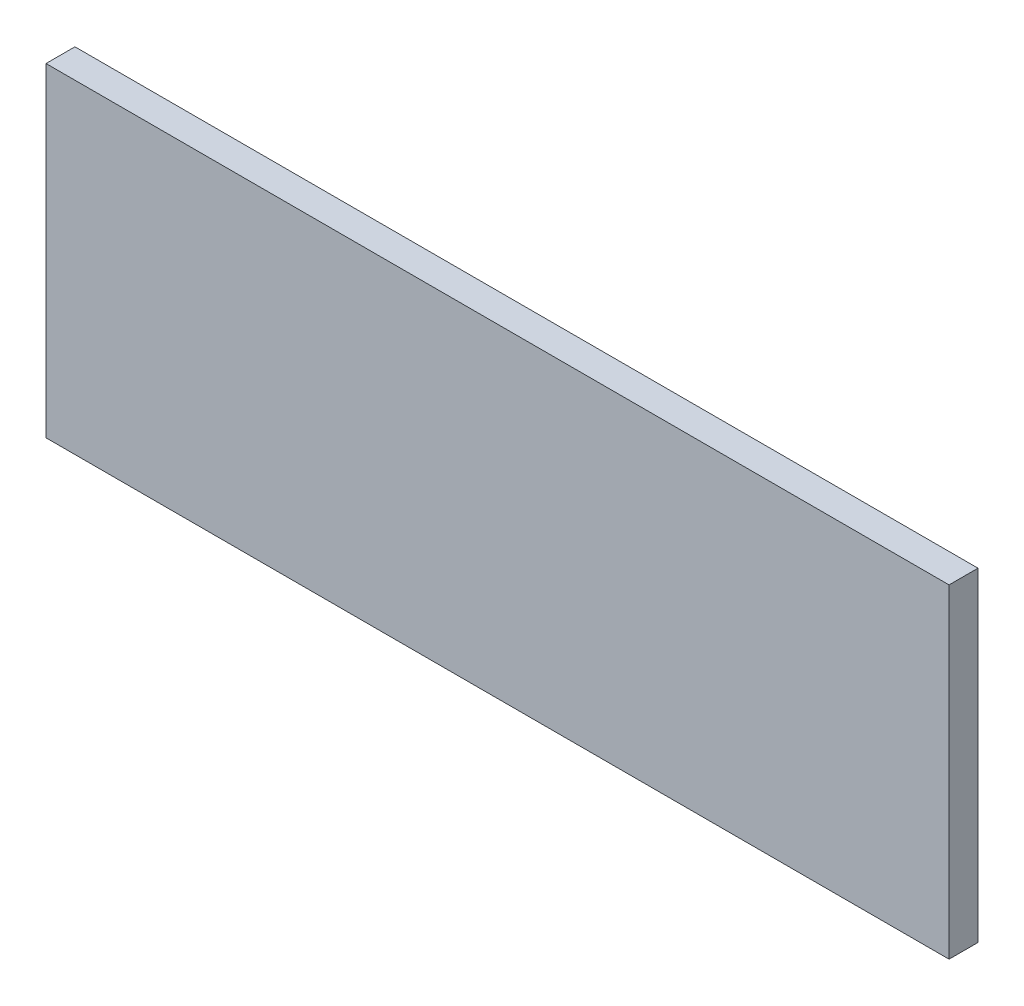
from build123d import *

# Parameters (mm, degrees)
SKETCH1_W           = 78
SKETCH1_H           = 28
BOSS_EXTRUDE1_DEPTH = 2.5


with BuildPart() as part:
    # Sketch1 → Boss-Extrude1 (new body)
    with BuildSketch(Plane.XY):
        with Locations((2.884955752, 2.921828909)):
            Rectangle(SKETCH1_W, SKETCH1_H)
    extrude(amount=BOSS_EXTRUDE1_DEPTH)


solid = part.part
